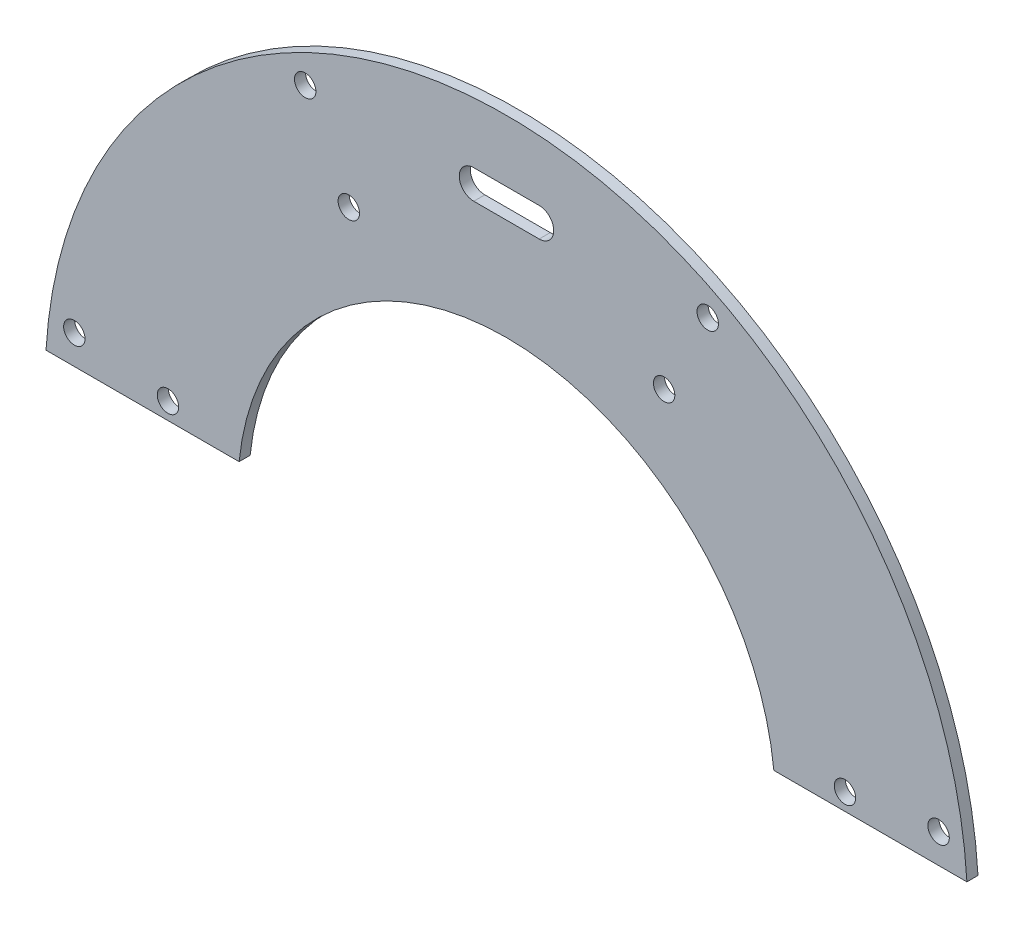
from build123d import *

# Parameters (mm, degrees)
BOSS_EXTRUDE1_DEPTH            = 0.762
F_4_CLEARANCE_HOLE1_AT_2_COUNT = 2
F_4_CLEARANCE_HOLE1_AT_2_PITCH = 13
CIRPATTERN1_COUNT              = 4
CIRPATTERN1_ANGLE              = 165
CUT_EXTRUDE1_DEPTH             = 2.524


with BuildPart() as part:
    # Sketch1 → Boss-Extrude1 (new body, symmetric)
    with BuildSketch(Plane.XY):
        with BuildLine():
            Line((-63.386197236, 3.8), (-36.804347569, 3.8))
            ThreePointArc((-36.804347569, 3.8), (0, 37), (36.804347569, 3.8))
            Line((36.804347569, 3.8), (63.386197236, 3.8))
            ThreePointArc((63.386197236, 3.8), (0, 63.5), (-63.386197236, 3.8))
        make_face()
    extrude(amount=BOSS_EXTRUDE1_DEPTH, both=True)

    # Sketch2 → #4 Clearance Hole1 (revolve, cut)
    with BuildSketch(Plane(origin=(-59.486691682, 7.831571533, 0.762), x_dir=(0, -1, 0), z_dir=(1, 0, 0))):
        Polygon((0, 0), (0, 136.775187864), (1.4732, 135.89), (1.4732, 0), align=None)
    f_4_clearance_hole1 = revolve(axis=Axis((-59.486691682, 7.831571533, 7.112), (0, 0, -1)), mode=Mode.SUBTRACT)

    # #4 Clearance Hole1 at 2: #4 Clearance Hole1 ×2
    with Locations(*[Vector(0.991444861, -0.130526192, 0) * (i * F_4_CLEARANCE_HOLE1_AT_2_PITCH) for i in range(1, F_4_CLEARANCE_HOLE1_AT_2_COUNT)]):
        add(f_4_clearance_hole1, mode=Mode.SUBTRACT)

    # CirPattern1: #4 Clearance Hole1 ×4 about axis
    cirpattern1_axis = Axis((0, 0, 0), (0, 0, -1))
    for i in range(1, CIRPATTERN1_COUNT):
        add(f_4_clearance_hole1.rotate(cirpattern1_axis, i * CIRPATTERN1_ANGLE / (CIRPATTERN1_COUNT - 1)), mode=Mode.SUBTRACT)

    # CirPattern1 copy 1 sketch → CirPattern1 copy 1 (revolve, cut)
    with BuildSketch(Plane(origin=(-21.702184822, 41.689509159, 0.762), x_dir=(-0.819152044, -0.573576436, 0), z_dir=(0.573576436, -0.819152044, 0))):
        Polygon((0, 0), (0, 136.775187864), (1.4732, 135.89), (1.4732, 0), align=None)
    revolve(axis=Axis((-21.702184822, 41.689509159, 7.112), (0, 0, -1)), mode=Mode.SUBTRACT)

    # CirPattern1 copy 2 sketch → CirPattern1 copy 2 (revolve, cut)
    with BuildSketch(Plane(origin=(21.702184822, 41.689509159, 0.762), x_dir=(-0.939692621, 0.342020143, 0), z_dir=(-0.342020143, -0.939692621, 0))):
        Polygon((0, 0), (0, 136.775187864), (1.4732, 135.89), (1.4732, 0), align=None)
    revolve(axis=Axis((21.702184822, 41.689509159, 7.112), (0, 0, -1)), mode=Mode.SUBTRACT)

    # CirPattern1 copy 3 sketch → CirPattern1 copy 3 (revolve, cut)
    with BuildSketch(Plane(origin=(46.597908485, 6.134731034, 0.762), x_dir=(-0.258819045, 0.965925826, 0), z_dir=(-0.965925826, -0.258819045, 0))):
        Polygon((0, 0), (0, 136.775187864), (1.4732, 135.89), (1.4732, 0), align=None)
    revolve(axis=Axis((46.597908485, 6.134731034, 7.112), (0, 0, -1)), mode=Mode.SUBTRACT)

    # Sketch4 → Cut-Extrude1 (cut, through all)
    with BuildSketch(Plane.XY.offset(0.762)):
        with BuildLine():
            Line((-4.5, 55), (4.5, 55))
            ThreePointArc((4.5, 55), (6.5, 53), (4.5, 51))
            Line((4.5, 51), (-4.5, 51))
            ThreePointArc((-4.5, 51), (-6.5, 53), (-4.5, 55))
        make_face()
    extrude(amount=-CUT_EXTRUDE1_DEPTH, mode=Mode.SUBTRACT)


solid = part.part
